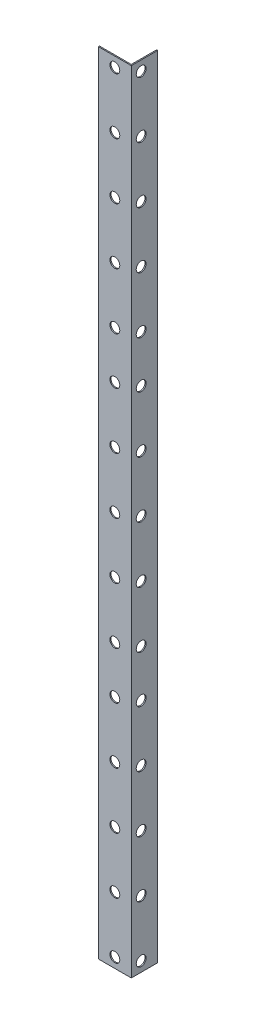
from build123d import *

# Parameters (mm, degrees)
BOSS_EXTRUDE1_DEPTH = 360
CUT_EXTRUDE1_REACH  = 2.5
SKETCH2_R           = 2.25
CUT_EXTRUDE2_REACH  = 14
SKETCH3_R           = 2.25


with BuildPart() as part:
    # Sketch1 → Boss-Extrude1 (new body)
    with BuildSketch(Plane(origin=(0, 0, 0), x_dir=(1, 0, 0), z_dir=(0, 1, 0))):
        Polygon((0, 0), (15, 0), (15, 12), (14.5, 12), (14.5, 0.5), (0, 0.5), align=None)
    extrude(amount=BOSS_EXTRUDE1_DEPTH)

    # Sketch2 → Cut-Extrude1 (cut, up to next)
    with BuildSketch(Plane.ZY.offset(-14.5), mode=Mode.PRIVATE) as cut_extrude1_sk1:
        with Locations((-4.5, 355.5)):
            Circle(SKETCH2_R)
    cut_extrude1_tool1 = extrude(cut_extrude1_sk1.sketch, amount=-CUT_EXTRUDE1_REACH, mode=Mode.PRIVATE) & part.part
    add(cut_extrude1_tool1.solids().sort_by_distance((14.5, 355.5, -4.5))[0], mode=Mode.SUBTRACT)
    # Sketch2 → Cut-Extrude1 (cut, up to next)
    with BuildSketch(Plane.ZY.offset(-14.5), mode=Mode.PRIVATE) as cut_extrude1_sk2:
        with Locations((-4.5, 329.8125)):
            Circle(SKETCH2_R)
    cut_extrude1_tool2 = extrude(cut_extrude1_sk2.sketch, amount=-CUT_EXTRUDE1_REACH, mode=Mode.PRIVATE) & part.part
    add(cut_extrude1_tool2.solids().sort_by_distance((14.5, 329.8125, -4.5))[0], mode=Mode.SUBTRACT)
    # Sketch2 → Cut-Extrude1 (cut, up to next)
    with BuildSketch(Plane.ZY.offset(-14.5), mode=Mode.PRIVATE) as cut_extrude1_sk3:
        with Locations((-4.5, 304.125)):
            Circle(SKETCH2_R)
    cut_extrude1_tool3 = extrude(cut_extrude1_sk3.sketch, amount=-CUT_EXTRUDE1_REACH, mode=Mode.PRIVATE) & part.part
    add(cut_extrude1_tool3.solids().sort_by_distance((14.5, 304.125, -4.5))[0], mode=Mode.SUBTRACT)
    # Sketch2 → Cut-Extrude1 (cut, up to next)
    with BuildSketch(Plane.ZY.offset(-14.5), mode=Mode.PRIVATE) as cut_extrude1_sk4:
        with Locations((-4.5, 278.4375)):
            Circle(SKETCH2_R)
    cut_extrude1_tool4 = extrude(cut_extrude1_sk4.sketch, amount=-CUT_EXTRUDE1_REACH, mode=Mode.PRIVATE) & part.part
    add(cut_extrude1_tool4.solids().sort_by_distance((14.5, 278.4375, -4.5))[0], mode=Mode.SUBTRACT)
    # Sketch2 → Cut-Extrude1 (cut, up to next)
    with BuildSketch(Plane.ZY.offset(-14.5), mode=Mode.PRIVATE) as cut_extrude1_sk5:
        with Locations((-4.5, 252.75)):
            Circle(SKETCH2_R)
    cut_extrude1_tool5 = extrude(cut_extrude1_sk5.sketch, amount=-CUT_EXTRUDE1_REACH, mode=Mode.PRIVATE) & part.part
    add(cut_extrude1_tool5.solids().sort_by_distance((14.5, 252.75, -4.5))[0], mode=Mode.SUBTRACT)
    # Sketch2 → Cut-Extrude1 (cut, up to next)
    with BuildSketch(Plane.ZY.offset(-14.5), mode=Mode.PRIVATE) as cut_extrude1_sk6:
        with Locations((-4.5, 231.375)):
            Circle(SKETCH2_R)
    cut_extrude1_tool6 = extrude(cut_extrude1_sk6.sketch, amount=-CUT_EXTRUDE1_REACH, mode=Mode.PRIVATE) & part.part
    add(cut_extrude1_tool6.solids().sort_by_distance((14.5, 231.375, -4.5))[0], mode=Mode.SUBTRACT)
    # Sketch2 → Cut-Extrude1 (cut, up to next)
    with BuildSketch(Plane.ZY.offset(-14.5), mode=Mode.PRIVATE) as cut_extrude1_sk7:
        with Locations((-4.5, 205.6875)):
            Circle(SKETCH2_R)
    cut_extrude1_tool7 = extrude(cut_extrude1_sk7.sketch, amount=-CUT_EXTRUDE1_REACH, mode=Mode.PRIVATE) & part.part
    add(cut_extrude1_tool7.solids().sort_by_distance((14.5, 205.6875, -4.5))[0], mode=Mode.SUBTRACT)
    # Sketch2 → Cut-Extrude1 (cut, up to next)
    with BuildSketch(Plane.ZY.offset(-14.5), mode=Mode.PRIVATE) as cut_extrude1_sk8:
        with Locations((-4.5, 180)):
            Circle(SKETCH2_R)
    cut_extrude1_tool8 = extrude(cut_extrude1_sk8.sketch, amount=-CUT_EXTRUDE1_REACH, mode=Mode.PRIVATE) & part.part
    add(cut_extrude1_tool8.solids().sort_by_distance((14.5, 180, -4.5))[0], mode=Mode.SUBTRACT)
    # Sketch2 → Cut-Extrude1 (cut, up to next)
    with BuildSketch(Plane.ZY.offset(-14.5), mode=Mode.PRIVATE) as cut_extrude1_sk9:
        with Locations((-4.5, 154.3125)):
            Circle(SKETCH2_R)
    cut_extrude1_tool9 = extrude(cut_extrude1_sk9.sketch, amount=-CUT_EXTRUDE1_REACH, mode=Mode.PRIVATE) & part.part
    add(cut_extrude1_tool9.solids().sort_by_distance((14.5, 154.3125, -4.5))[0], mode=Mode.SUBTRACT)
    # Sketch2 → Cut-Extrude1 (cut, up to next)
    with BuildSketch(Plane.ZY.offset(-14.5), mode=Mode.PRIVATE) as cut_extrude1_sk10:
        with Locations((-4.5, 128.625)):
            Circle(SKETCH2_R)
    cut_extrude1_tool10 = extrude(cut_extrude1_sk10.sketch, amount=-CUT_EXTRUDE1_REACH, mode=Mode.PRIVATE) & part.part
    add(cut_extrude1_tool10.solids().sort_by_distance((14.5, 128.625, -4.5))[0], mode=Mode.SUBTRACT)
    # Sketch2 → Cut-Extrude1 (cut, up to next)
    with BuildSketch(Plane.ZY.offset(-14.5), mode=Mode.PRIVATE) as cut_extrude1_sk11:
        with Locations((-4.5, 107.25)):
            Circle(SKETCH2_R)
    cut_extrude1_tool11 = extrude(cut_extrude1_sk11.sketch, amount=-CUT_EXTRUDE1_REACH, mode=Mode.PRIVATE) & part.part
    add(cut_extrude1_tool11.solids().sort_by_distance((14.5, 107.25, -4.5))[0], mode=Mode.SUBTRACT)
    # Sketch2 → Cut-Extrude1 (cut, up to next)
    with BuildSketch(Plane.ZY.offset(-14.5), mode=Mode.PRIVATE) as cut_extrude1_sk12:
        with Locations((-4.5, 81.5625)):
            Circle(SKETCH2_R)
    cut_extrude1_tool12 = extrude(cut_extrude1_sk12.sketch, amount=-CUT_EXTRUDE1_REACH, mode=Mode.PRIVATE) & part.part
    add(cut_extrude1_tool12.solids().sort_by_distance((14.5, 81.5625, -4.5))[0], mode=Mode.SUBTRACT)
    # Sketch2 → Cut-Extrude1 (cut, up to next)
    with BuildSketch(Plane.ZY.offset(-14.5), mode=Mode.PRIVATE) as cut_extrude1_sk13:
        with Locations((-4.5, 55.875)):
            Circle(SKETCH2_R)
    cut_extrude1_tool13 = extrude(cut_extrude1_sk13.sketch, amount=-CUT_EXTRUDE1_REACH, mode=Mode.PRIVATE) & part.part
    add(cut_extrude1_tool13.solids().sort_by_distance((14.5, 55.875, -4.5))[0], mode=Mode.SUBTRACT)
    # Sketch2 → Cut-Extrude1 (cut, up to next)
    with BuildSketch(Plane.ZY.offset(-14.5), mode=Mode.PRIVATE) as cut_extrude1_sk14:
        with Locations((-4.5, 30.1875)):
            Circle(SKETCH2_R)
    cut_extrude1_tool14 = extrude(cut_extrude1_sk14.sketch, amount=-CUT_EXTRUDE1_REACH, mode=Mode.PRIVATE) & part.part
    add(cut_extrude1_tool14.solids().sort_by_distance((14.5, 30.1875, -4.5))[0], mode=Mode.SUBTRACT)
    # Sketch2 → Cut-Extrude1 (cut, up to next)
    with BuildSketch(Plane.ZY.offset(-14.5), mode=Mode.PRIVATE) as cut_extrude1_sk15:
        with Locations((-4.5, 4.5)):
            Circle(SKETCH2_R)
    cut_extrude1_tool15 = extrude(cut_extrude1_sk15.sketch, amount=-CUT_EXTRUDE1_REACH, mode=Mode.PRIVATE) & part.part
    add(cut_extrude1_tool15.solids().sort_by_distance((14.5, 4.5, -4.5))[0], mode=Mode.SUBTRACT)

    # Sketch3 → Cut-Extrude2 (cut, up to next)
    with BuildSketch(Plane.XY, mode=Mode.PRIVATE) as cut_extrude2_sk1:
        with Locations((7.5, 355.5)):
            Circle(SKETCH3_R)
    cut_extrude2_tool1 = extrude(cut_extrude2_sk1.sketch, amount=-CUT_EXTRUDE2_REACH, mode=Mode.PRIVATE) & part.part
    add(cut_extrude2_tool1.solids().sort_by_distance((7.5, 355.5, 0))[0], mode=Mode.SUBTRACT)
    # Sketch3 → Cut-Extrude2 (cut, up to next)
    with BuildSketch(Plane.XY, mode=Mode.PRIVATE) as cut_extrude2_sk2:
        with Locations((7.5, 329.84375)):
            Circle(SKETCH3_R)
    cut_extrude2_tool2 = extrude(cut_extrude2_sk2.sketch, amount=-CUT_EXTRUDE2_REACH, mode=Mode.PRIVATE) & part.part
    add(cut_extrude2_tool2.solids().sort_by_distance((7.5, 329.84375, 0))[0], mode=Mode.SUBTRACT)
    # Sketch3 → Cut-Extrude2 (cut, up to next)
    with BuildSketch(Plane.XY, mode=Mode.PRIVATE) as cut_extrude2_sk3:
        with Locations((7.5, 304.1875)):
            Circle(SKETCH3_R)
    cut_extrude2_tool3 = extrude(cut_extrude2_sk3.sketch, amount=-CUT_EXTRUDE2_REACH, mode=Mode.PRIVATE) & part.part
    add(cut_extrude2_tool3.solids().sort_by_distance((7.5, 304.1875, 0))[0], mode=Mode.SUBTRACT)
    # Sketch3 → Cut-Extrude2 (cut, up to next)
    with BuildSketch(Plane.XY, mode=Mode.PRIVATE) as cut_extrude2_sk4:
        with Locations((7.5, 278.53125)):
            Circle(SKETCH3_R)
    cut_extrude2_tool4 = extrude(cut_extrude2_sk4.sketch, amount=-CUT_EXTRUDE2_REACH, mode=Mode.PRIVATE) & part.part
    add(cut_extrude2_tool4.solids().sort_by_distance((7.5, 278.53125, 0))[0], mode=Mode.SUBTRACT)
    # Sketch3 → Cut-Extrude2 (cut, up to next)
    with BuildSketch(Plane.XY, mode=Mode.PRIVATE) as cut_extrude2_sk5:
        with Locations((7.5, 252.875)):
            Circle(SKETCH3_R)
    cut_extrude2_tool5 = extrude(cut_extrude2_sk5.sketch, amount=-CUT_EXTRUDE2_REACH, mode=Mode.PRIVATE) & part.part
    add(cut_extrude2_tool5.solids().sort_by_distance((7.5, 252.875, 0))[0], mode=Mode.SUBTRACT)
    # Sketch3 → Cut-Extrude2 (cut, up to next)
    with BuildSketch(Plane.XY, mode=Mode.PRIVATE) as cut_extrude2_sk6:
        with Locations((7.5, 231.3125)):
            Circle(SKETCH3_R)
    cut_extrude2_tool6 = extrude(cut_extrude2_sk6.sketch, amount=-CUT_EXTRUDE2_REACH, mode=Mode.PRIVATE) & part.part
    add(cut_extrude2_tool6.solids().sort_by_distance((7.5, 231.3125, 0))[0], mode=Mode.SUBTRACT)
    # Sketch3 → Cut-Extrude2 (cut, up to next)
    with BuildSketch(Plane.XY, mode=Mode.PRIVATE) as cut_extrude2_sk7:
        with Locations((7.5, 205.65625)):
            Circle(SKETCH3_R)
    cut_extrude2_tool7 = extrude(cut_extrude2_sk7.sketch, amount=-CUT_EXTRUDE2_REACH, mode=Mode.PRIVATE) & part.part
    add(cut_extrude2_tool7.solids().sort_by_distance((7.5, 205.65625, 0))[0], mode=Mode.SUBTRACT)
    # Sketch3 → Cut-Extrude2 (cut, up to next)
    with BuildSketch(Plane.XY, mode=Mode.PRIVATE) as cut_extrude2_sk8:
        with Locations((7.5, 180)):
            Circle(SKETCH3_R)
    cut_extrude2_tool8 = extrude(cut_extrude2_sk8.sketch, amount=-CUT_EXTRUDE2_REACH, mode=Mode.PRIVATE) & part.part
    add(cut_extrude2_tool8.solids().sort_by_distance((7.5, 180, 0))[0], mode=Mode.SUBTRACT)
    # Sketch3 → Cut-Extrude2 (cut, up to next)
    with BuildSketch(Plane.XY, mode=Mode.PRIVATE) as cut_extrude2_sk9:
        with Locations((7.5, 154.34375)):
            Circle(SKETCH3_R)
    cut_extrude2_tool9 = extrude(cut_extrude2_sk9.sketch, amount=-CUT_EXTRUDE2_REACH, mode=Mode.PRIVATE) & part.part
    add(cut_extrude2_tool9.solids().sort_by_distance((7.5, 154.34375, 0))[0], mode=Mode.SUBTRACT)
    # Sketch3 → Cut-Extrude2 (cut, up to next)
    with BuildSketch(Plane.XY, mode=Mode.PRIVATE) as cut_extrude2_sk10:
        with Locations((7.5, 128.6875)):
            Circle(SKETCH3_R)
    cut_extrude2_tool10 = extrude(cut_extrude2_sk10.sketch, amount=-CUT_EXTRUDE2_REACH, mode=Mode.PRIVATE) & part.part
    add(cut_extrude2_tool10.solids().sort_by_distance((7.5, 128.6875, 0))[0], mode=Mode.SUBTRACT)
    # Sketch3 → Cut-Extrude2 (cut, up to next)
    with BuildSketch(Plane.XY, mode=Mode.PRIVATE) as cut_extrude2_sk11:
        with Locations((7.5, 107.125)):
            Circle(SKETCH3_R)
    cut_extrude2_tool11 = extrude(cut_extrude2_sk11.sketch, amount=-CUT_EXTRUDE2_REACH, mode=Mode.PRIVATE) & part.part
    add(cut_extrude2_tool11.solids().sort_by_distance((7.5, 107.125, 0))[0], mode=Mode.SUBTRACT)
    # Sketch3 → Cut-Extrude2 (cut, up to next)
    with BuildSketch(Plane.XY, mode=Mode.PRIVATE) as cut_extrude2_sk12:
        with Locations((7.5, 81.46875)):
            Circle(SKETCH3_R)
    cut_extrude2_tool12 = extrude(cut_extrude2_sk12.sketch, amount=-CUT_EXTRUDE2_REACH, mode=Mode.PRIVATE) & part.part
    add(cut_extrude2_tool12.solids().sort_by_distance((7.5, 81.46875, 0))[0], mode=Mode.SUBTRACT)
    # Sketch3 → Cut-Extrude2 (cut, up to next)
    with BuildSketch(Plane.XY, mode=Mode.PRIVATE) as cut_extrude2_sk13:
        with Locations((7.5, 55.8125)):
            Circle(SKETCH3_R)
    cut_extrude2_tool13 = extrude(cut_extrude2_sk13.sketch, amount=-CUT_EXTRUDE2_REACH, mode=Mode.PRIVATE) & part.part
    add(cut_extrude2_tool13.solids().sort_by_distance((7.5, 55.8125, 0))[0], mode=Mode.SUBTRACT)
    # Sketch3 → Cut-Extrude2 (cut, up to next)
    with BuildSketch(Plane.XY, mode=Mode.PRIVATE) as cut_extrude2_sk14:
        with Locations((7.5, 30.15625)):
            Circle(SKETCH3_R)
    cut_extrude2_tool14 = extrude(cut_extrude2_sk14.sketch, amount=-CUT_EXTRUDE2_REACH, mode=Mode.PRIVATE) & part.part
    add(cut_extrude2_tool14.solids().sort_by_distance((7.5, 30.15625, 0))[0], mode=Mode.SUBTRACT)
    # Sketch3 → Cut-Extrude2 (cut, up to next)
    with BuildSketch(Plane.XY, mode=Mode.PRIVATE) as cut_extrude2_sk15:
        with Locations((7.5, 4.5)):
            Circle(SKETCH3_R)
    cut_extrude2_tool15 = extrude(cut_extrude2_sk15.sketch, amount=-CUT_EXTRUDE2_REACH, mode=Mode.PRIVATE) & part.part
    add(cut_extrude2_tool15.solids().sort_by_distance((7.5, 4.5, 0))[0], mode=Mode.SUBTRACT)


solid = part.part
